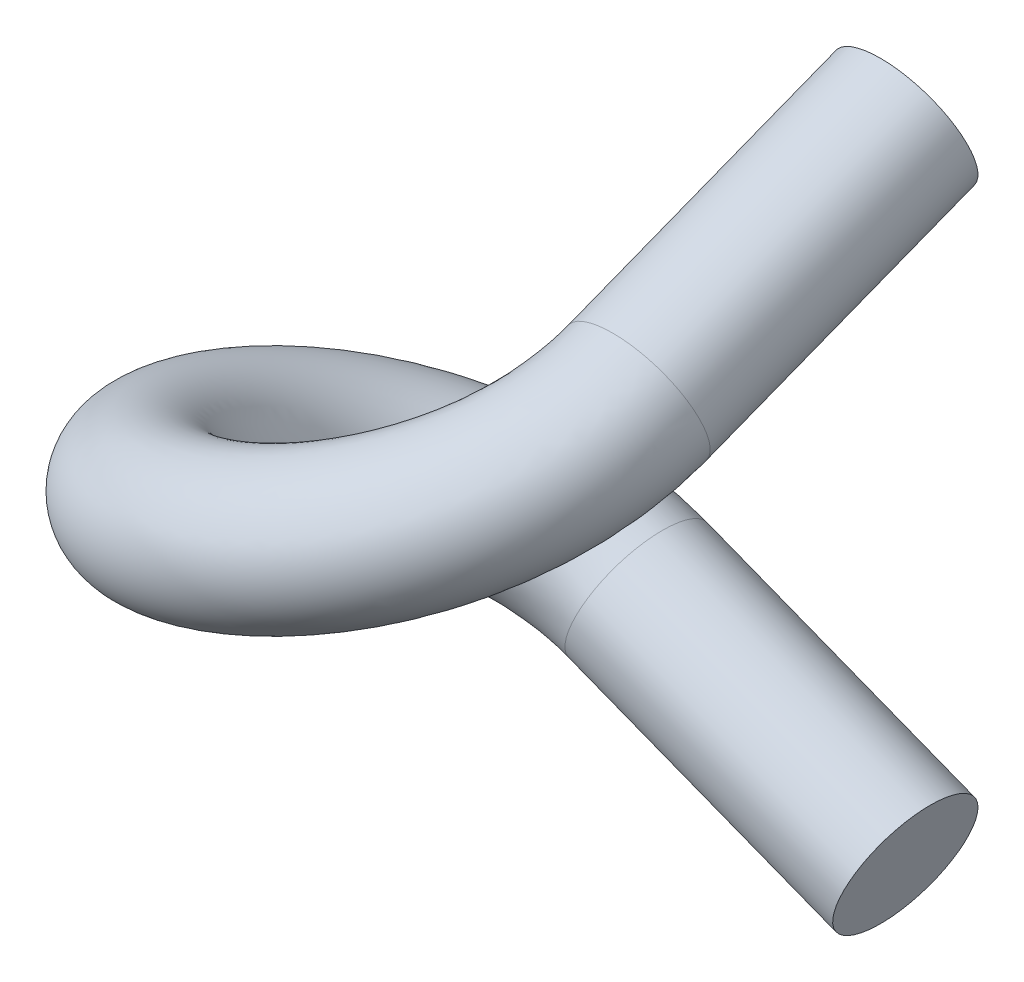
from build123d import *

# Parameters (mm, degrees)
SKIZZE5_R = 3


with BuildPart() as part:
    # Austragung1: sweep along a curve in space
    with BuildLine() as austragung1_path:
        Line((0, -16.5, -9), (11.753641908, -21.072700511, -9))
        add(Edge.make_bspline(
            [(9, 0, 0), (9, -0.455781461, 1.171537929), (8.531386838, -1.376184325, 3.536786751), (6.529640822, -2.749682669, 6.528844827), (3.533816058, -4.125084999, 8.531600125), (2.95e-07, -5.499977333, 9.23424943), (-3.533817236, -6.875005667, 8.531402157), (-6.529636698, -8.25, 6.529636698), (-8.531402157, -9.624994333, 3.533817236), (-9.23424943, -11.000022667, -2.95e-07), (-8.531600125, -12.374915001, -3.533816058), (-6.528844827, -13.750317331, -6.529640822), (-3.536786751, -15.123815675, -8.531386838), (-1.171537929, -16.044218539, -9), (0, -16.5, -9)],
            knots=[0, 0, 0, 0, 0.083333333, 0.166666667, 0.25, 0.333333333, 0.416666667, 0.5, 0.583333333, 0.666666667, 0.75, 0.833333333, 0.916666667, 1, 1, 1, 1], degree=3))
        Line((9, 0, 0), (9, 4.572700511, -11.753641908))
    # Skizze5 → Austragung1 (sweep)
    with BuildSketch(Plane(origin=(9, 4.572700511, -11.753641908), x_dir=(-1, 0, 0), z_dir=(0, 0.362572971, -0.931955386))):
        Circle(SKIZZE5_R)
    sweep(path=austragung1_path.line)


solid = part.part
